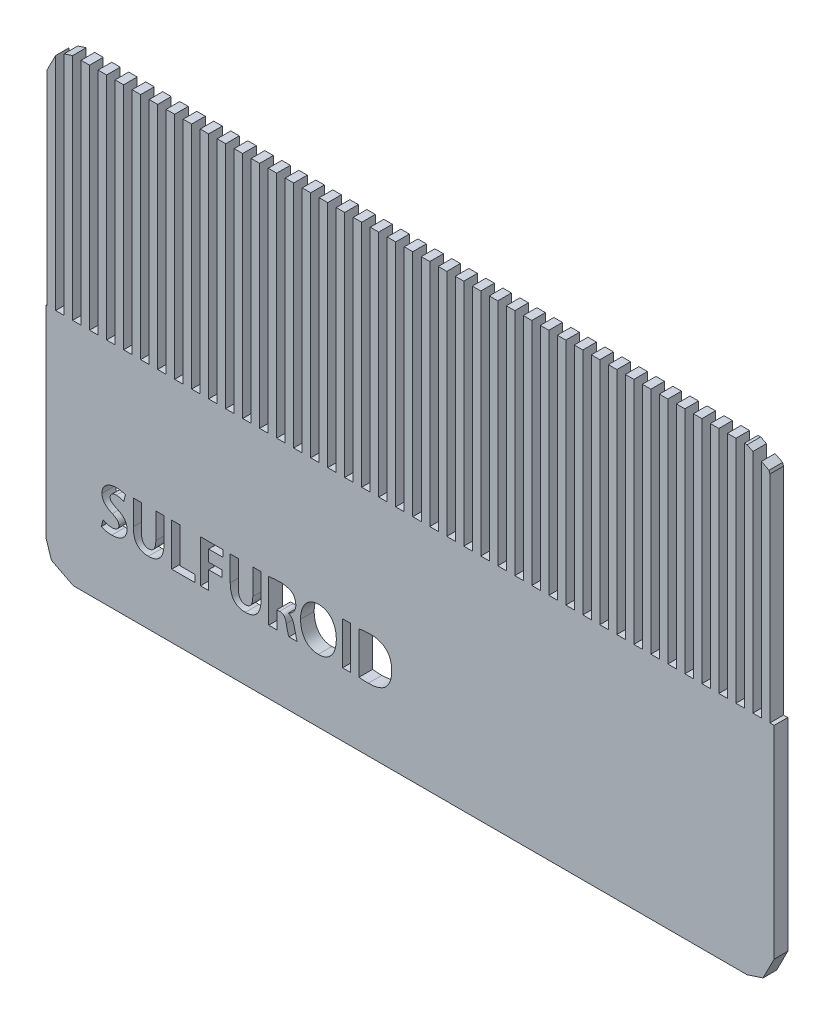
from build123d import *

# Parameters (mm, degrees)
BOSS_EXTRU_1_DEPTH      = 1.6
ESQUISSE2_W             = 0.957768643
ESQUISSE2_H             = 5
ENL_V_MAT_EXTRU_1_DEPTH = 1.6
ESQUISSE3_W             = 1.870037925
ESQUISSE3_H             = 1.835881981
ESQUISSE3_W_2           = 2.301837367
ESQUISSE3_H_2           = 4.041085352
ENL_V_MAT_EXTRU_2_DEPTH = 1.6
ESQUISSE4_W             = 2.558375981
ESQUISSE4_H             = 3.956558203
ENL_V_MAT_EXTRU_3_DEPTH = 1.6


with BuildPart() as part:
    # Model → Boss.-Extru.1 (new body)
    with BuildSketch(Plane.XY):
        Polygon((39.3, 0), (38.3, 0), (38.3, 26.99), (37.3, 26.99), (37.3, 0), (36.3, 0), (36.3, 26.99), (35.3, 26.99), (35.3, 0), (34.3, 0), (34.3, 26.99), (33.3, 26.99), (33.3, 0), (32.3, 0), (32.3, 26.99), (31.3, 26.99), (31.3, 0), (30.3, 0), (30.3, 26.99), (29.3, 26.99), (29.3, 0), (28.3, 0), (28.3, 26.99), (27.3, 26.99), (27.3, 0), (26.3, 0), (26.3, 26.99), (25.3, 26.99), (25.3, 0), (24.3, 0), (24.3, 26.99), (23.3, 26.99), (23.3, 0), (22.3, 0), (22.3, 26.99), (21.3, 26.99), (21.3, 0), (20.3, 0), (20.3, 26.99), (19.3, 26.99), (19.3, 0), (18.3, 0), (18.3, 26.99), (17.3, 26.99), (17.3, 0), (16.3, 0), (16.3, 26.99), (15.3, 26.99), (15.3, 0), (14.3, 0), (14.3, 26.99), (13.3, 26.99), (13.3, 0), (12.3, 0), (12.3, 26.99), (11.3, 26.99), (11.3, 0), (10.3, 0), (10.3, 26.99), (9.29999, 26.99), (9.29999, 0), (8.29999, 0), (8.29999, 26.99), (7.29999, 26.99), (7.29999, 0), (6.29999, 0), (6.29999, 26.99), (5.29999, 26.99), (5.29999, 0), (4.29999, 0), (4.29999, 26.99), (3.29999, 26.99), (3.29999, 0), (2.29999, 0), (2.29999, 26.99), (1.29999, 26.99), (1.29999, 0), (0.299988, 0), (0.299988, 26.99), (-0.699997, 26.99), (-0.699997, 0), (-1.7, 0), (-1.7, 26.99), (-2.7, 26.99), (-2.7, 0), (-3.7, 0), (-3.7, 26.99), (-4.7, 26.99), (-4.7, 0), (-5.7, 0), (-5.7, 26.99), (-6.7, 26.99), (-6.7, 0), (-7.7, 0), (-7.7, 26.99), (-8.7, 26.99), (-8.7, 0), (-9.7, 0), (-9.7, 26.99), (-10.7, 26.99), (-10.7, 0), (-11.7, 0), (-11.7, 26.99), (-12.7, 26.99), (-12.7, 0), (-13.7, 0), (-13.7, 26.99), (-14.7, 26.99), (-14.7, 0), (-15.7, 0), (-15.7, 26.99), (-16.7, 26.99), (-16.7, 0), (-17.7, 0), (-17.7, 26.99), (-18.7, 26.99), (-18.7, 0), (-19.7, 0), (-19.7, 26.99), (-20.7, 26.99), (-20.7, 0), (-21.7, 0), (-21.7, 26.99), (-22.7, 26.99), (-22.7, 0), (-23.7, 0), (-23.7, 26.99), (-24.7, 26.99), (-24.7, 0), (-25.7, 0), (-25.7, 26.99), (-26.7, 26.99), (-26.7, 0), (-27.7, 0), (-27.7, 26.99), (-28.7, 26.99), (-28.7, 0), (-29.7, 0), (-29.7, 26.99), (-30.7, 26.99), (-30.7, 0), (-31.7, 0), (-31.7, 26.99), (-32.7, 26.99), (-32.7, 0), (-33.7, 0), (-33.7, 26.99), (-34.7, 26.99), (-34.7, 0), (-35.7, 0), (-35.7, 26.99), (-36.7, 26.99), (-36.7, 0), (-37.7, 0), (-37.7, 26.99), (-38.7, 26.99), (-38.7, 0), (-39.7, 0), (-39.7, 26.964), (-40.7, 26.6391), (-40.7, 0), (-41.7, 0), (-41.7, 25.9689), (-42.7, 24.0062), (-42.7, 0), (-42.8, 0), (-42.8, -23.81), (-42.1927, -25.6792), (-39.62, -26.99), (39.62, -26.99), (41.4892, -26.3827), (42.8, -23.81), (42.8, 0), (42.3, 0), (42.3, 25.3489), (42.1927, 25.6792), (41.3, 26.134), (41.3, 0), (40.3, 0), (40.3, 26.6435), (39.62, 26.99), (39.3, 26.99), align=None)
    extrude(amount=BOSS_EXTRU_1_DEPTH)

    # Esquisse2 → Enlèv. mat.-Extru.1 (cut)
    with BuildSketch(Plane.XY.offset(1.6)):
        with BuildLine():
            add(Edge.make_bspline(
                [(-36.312470517, -19.306454231), (-36.279474655, -19.324711699), (-36.209064635, -19.363671391), (-36.088962995, -19.409811898), (-35.952171821, -19.455778709), (-35.798193871, -19.49473218), (-35.632974565, -19.529762273), (-35.459494376, -19.554980365), (-35.280421383, -19.571360242), (-35.158858991, -19.574328257), (-35.09723478, -19.575832847)],
                knots=[0, 0, 0, 0, 0.000113007, 0.000241146, 0.00038513, 0.000545869, 0.000717253, 0.000891632, 0.001071458, 0.001256342, 0.001256342, 0.001256342, 0.001256342], degree=3))
            add(Edge.make_bspline(
                [(-35.09723478, -19.575832847), (-35.027093735, -19.574069767), (-34.890559652, -19.570637816), (-34.692582293, -19.547979016), (-34.506627472, -19.516173066), (-34.333807634, -19.469321879), (-34.172521707, -19.412776218), (-34.024586927, -19.341417012), (-33.88891563, -19.258252947), (-33.76604355, -19.163240207), (-33.657978813, -19.056815715), (-33.561273009, -18.944188793), (-33.482434598, -18.820903897), (-33.415125111, -18.691430687), (-33.364878924, -18.5523391), (-33.326277761, -18.405838764), (-33.305205447, -18.250390121), (-33.301449673, -18.144265402), (-33.299534931, -18.090161656)],
                knots=[0, 0, 0, 0, 0.00021039, 0.000409537, 0.000597226, 0.000775815, 0.000946076, 0.001109247, 0.001267531, 0.00142272, 0.001574046, 0.001721904, 0.001867019, 0.002012049, 0.002158793, 0.002309696, 0.002465809, 0.002628173, 0.002628173, 0.002628173, 0.002628173], degree=3))
            add(Edge.make_bspline(
                [(-33.299534931, -18.090161656), (-33.300208149, -18.049602103), (-33.301536913, -17.969547668), (-33.313596729, -17.851511987), (-33.33606334, -17.738027787), (-33.364325348, -17.627713701), (-33.404788362, -17.522634571), (-33.451671255, -17.420623841), (-33.508834342, -17.323555707), (-33.573949614, -17.229592281), (-33.649168188, -17.139834987), (-33.733415227, -17.052695485), (-33.827683966, -16.968930879), (-33.932311978, -16.889006992), (-34.045225154, -16.810240783), (-34.168969833, -16.736195827), (-34.302409671, -16.665493425), (-34.395385703, -16.621413675), (-34.443011552, -16.598834356)],
                knots=[0, 0, 0, 0, 0.000121665, 0.000240136, 0.000355317, 0.000468506, 0.000581266, 0.000692603, 0.000804972, 0.000918729, 0.001035203, 0.00115587, 0.001282067, 0.001413114, 0.001550659, 0.001694868, 0.00184542, 0.002003527, 0.002003527, 0.002003527, 0.002003527], degree=3))
            add(Edge.make_bspline(
                [(-34.443011552, -16.598834356), (-34.47921524, -16.58232534), (-34.549432804, -16.550305871), (-34.65013341, -16.501509092), (-34.742809284, -16.453298735), (-34.827678512, -16.406151404), (-34.905463833, -16.360296557), (-34.97470925, -16.313840804), (-35.037327289, -16.27008434), (-35.091913342, -16.226119307), (-35.139925162, -16.181728193), (-35.180778454, -16.134333427), (-35.215108077, -16.083655738), (-35.24326105, -16.030663857), (-35.264415684, -15.974496096), (-35.279144599, -15.915990781), (-35.289441318, -15.854473453), (-35.289508376, -15.812364412), (-35.289542472, -15.790953511)],
                knots=[0, 0, 0, 0, 0.000119368, 0.000231516, 0.00033566, 0.000432715, 0.000522765, 0.000606431, 0.000682811, 0.000751859, 0.000816549, 0.000878716, 0.000939114, 0.000999835, 0.001058312, 0.001118673, 0.001180668, 0.001244799, 0.001244799, 0.001244799, 0.001244799], degree=3))
            add(Edge.make_bspline(
                [(-35.289542472, -15.790953511), (-35.287676923, -15.755197213), (-35.283982217, -15.684382135), (-35.250128276, -15.581847684), (-35.194096262, -15.486942667), (-35.129803971, -15.41630366), (-35.068154285, -15.365069788), (-35.013988356, -15.331520831), (-34.954288047, -15.301656825), (-34.887712784, -15.279015732), (-34.815888017, -15.258529919), (-34.737548704, -15.244817293), (-34.653069691, -15.236676125), (-34.594800549, -15.234178083), (-34.564617887, -15.23288413)],
                knots=[0, 0, 0, 0, 0.000107027, 0.000211966, 0.000320129, 0.000435603, 0.000496557, 0.00056011, 0.000626299, 0.00069637, 0.000770698, 0.000850209, 0.000934535, 0.001025156, 0.001025156, 0.001025156, 0.001025156], degree=3))
            add(Edge.make_bspline(
                [(-34.564617887, -15.23288413), (-34.515566178, -15.234507902), (-34.420724301, -15.237647478), (-34.283643184, -15.251572473), (-34.156978552, -15.274037661), (-34.040935236, -15.304252315), (-33.936261524, -15.339792654), (-33.841825968, -15.373916214), (-33.758935272, -15.40969258), (-33.708825966, -15.436202981), (-33.685093, -15.448758941)],
                knots=[0, 0, 0, 0, 0.000147207, 0.000284626, 0.000412955, 0.000532765, 0.000643958, 0.000744472, 0.000833968, 0.000914494, 0.000914494, 0.000914494, 0.000914494], degree=3))
            Line((-33.685093, -15.448758941), (-33.485053267, -14.676201157))
            add(Edge.make_bspline(
                [(-33.485053267, -14.676201157), (-33.516111292, -14.661978576), (-33.5809105, -14.632304697), (-33.685102768, -14.590767167), (-33.802130251, -14.556816242), (-33.929170088, -14.521594987), (-34.068085867, -14.493963661), (-34.217730561, -14.471677906), (-34.378430393, -14.46036957), (-34.488876021, -14.45755936), (-34.545764192, -14.456111882)],
                knots=[0, 0, 0, 0, 0.000102483, 0.00021382, 0.000336078, 0.000467788, 0.000609219, 0.000760666, 0.00092139, 0.00109211, 0.00109211, 0.00109211, 0.00109211], degree=3))
            add(Edge.make_bspline(
                [(-34.545764192, -14.456111882), (-34.611176688, -14.458402126), (-34.738543398, -14.46286153), (-34.923555915, -14.483514234), (-35.097302788, -14.516337341), (-35.259658203, -14.561600539), (-35.411461218, -14.617864557), (-35.551780022, -14.686923521), (-35.680918361, -14.768218678), (-35.797563744, -14.861854287), (-35.902455156, -14.964231436), (-35.99317631, -15.075305102), (-36.071434004, -15.192649488), (-36.134963447, -15.317970298), (-36.18386582, -15.450690162), (-36.219670952, -15.590275747), (-36.243073928, -15.737078122), (-36.2465037, -15.837683892), (-36.248252879, -15.888992727)],
                knots=[0, 0, 0, 0, 0.000196305, 0.000382231, 0.00055787, 0.000726207, 0.000887293, 0.001042859, 0.001194546, 0.001344124, 0.001490778, 0.001633447, 0.001773587, 0.001913133, 0.002053919, 0.002197049, 0.002344906, 0.002498798, 0.002498798, 0.002498798, 0.002498798], degree=3))
            add(Edge.make_bspline(
                [(-36.248252879, -15.888992727), (-36.246752181, -15.929269051), (-36.243786272, -16.008869277), (-36.227214789, -16.126155538), (-36.202231192, -16.239602502), (-36.166138958, -16.348867158), (-36.119300569, -16.453402589), (-36.065029126, -16.555033417), (-35.999214783, -16.651660872), (-35.923485097, -16.743767381), (-35.839732155, -16.832004589), (-35.748319396, -16.916578462), (-35.649497791, -16.997530918), (-35.542368115, -17.074600796), (-35.428598294, -17.149799034), (-35.305474893, -17.218441734), (-35.176282426, -17.286502), (-35.085854406, -17.326781328), (-35.039731009, -17.34732606)],
                knots=[0, 0, 0, 0, 0.000120844, 0.00023883, 0.000354781, 0.000468954, 0.000583334, 0.000698067, 0.000814155, 0.000933411, 0.001055441, 0.001178846, 0.001306791, 0.001438406, 0.00157463, 0.001715642, 0.001861103, 0.002012536, 0.002012536, 0.002012536, 0.002012536], degree=3))
            add(Edge.make_bspline(
                [(-35.039731009, -17.34732606), (-34.9757991, -17.376251168), (-34.855452468, -17.430700337), (-34.692103199, -17.521653059), (-34.55506601, -17.612845027), (-34.444994637, -17.708414011), (-34.357948474, -17.808848323), (-34.299182663, -17.920496558), (-34.261851161, -18.041276525), (-34.258841694, -18.125389253), (-34.257302653, -18.168404492)],
                knots=[0, 0, 0, 0, 0.00021043, 0.000396117, 0.000560318, 0.000703271, 0.000832418, 0.000956409, 0.001079299, 0.001207922, 0.001207922, 0.001207922, 0.001207922], degree=3))
            add(Edge.make_bspline(
                [(-34.257302653, -18.168404492), (-34.257745864, -18.191692007), (-34.258612238, -18.237213638), (-34.268307565, -18.303581771), (-34.28412283, -18.366290465), (-34.307341498, -18.425100739), (-34.335313919, -18.481142243), (-34.370588326, -18.533312136), (-34.412398465, -18.581665386), (-34.460506491, -18.625891728), (-34.514608117, -18.665623394), (-34.574575159, -18.700780064), (-34.640560705, -18.730834446), (-34.71257743, -18.755344452), (-34.790602851, -18.773916987), (-34.874338819, -18.788124242), (-34.964472371, -18.796396524), (-35.026517253, -18.798152854), (-35.058584704, -18.7990606)],
                knots=[0, 0, 0, 0, 6.9816e-05, 0.000136474, 0.000200722, 0.000263394, 0.00032579, 0.000388278, 0.000451775, 0.000517154, 0.000583898, 0.000652772, 0.000725328, 0.000801049, 0.000880615, 0.000965697, 0.001055653, 0.001151881, 0.001151881, 0.001151881, 0.001151881], degree=3))
            add(Edge.make_bspline(
                [(-35.058584704, -18.7990606), (-35.108892106, -18.797434691), (-35.208771907, -18.794206626), (-35.357219432, -18.779271406), (-35.502648759, -18.753545182), (-35.643964043, -18.718930449), (-35.778455758, -18.676634093), (-35.904338994, -18.629853179), (-36.01981336, -18.57744101), (-36.091097528, -18.536886067), (-36.12570386, -18.517197855)],
                knots=[0, 0, 0, 0, 0.000150974, 0.000299742, 0.00044713, 0.000593686, 0.000735907, 0.000869851, 0.000996395, 0.001115793, 0.001115793, 0.001115793, 0.001115793], degree=3))
            Line((-36.12570386, -18.517197855), (-36.312470517, -19.306454231))
        make_face()
        with BuildLine():
            Line((-29.912470407, -14.515501943), (-29.912470407, -17.538004307))
            add(Edge.make_bspline(
                [(-29.912470407, -17.538004307), (-29.913512385, -17.591674246), (-29.915521021, -17.695134522), (-29.926931296, -17.844189078), (-29.94432453, -17.981873326), (-29.969700589, -18.108171888), (-30.001525298, -18.223598771), (-30.03974418, -18.328129043), (-30.086054834, -18.42100553), (-30.139064335, -18.503057926), (-30.198697125, -18.573899718), (-30.263785552, -18.635382454), (-30.334244253, -18.687279048), (-30.410710151, -18.729222677), (-30.492441872, -18.761471834), (-30.579522851, -18.783830256), (-30.672147953, -18.797520074), (-30.73569707, -18.798536907), (-30.768426333, -18.7990606)],
                knots=[0, 0, 0, 0, 0.000161012, 0.000310385, 0.000448243, 0.000577102, 0.000696492, 0.000807156, 0.000910443, 0.001007187, 0.001099522, 0.001187551, 0.001275225, 0.001361294, 0.001448471, 0.0015381, 0.001630488, 0.0017286, 0.0017286, 0.0017286, 0.0017286], degree=3))
            add(Edge.make_bspline(
                [(-30.768426333, -18.7990606), (-30.79957678, -18.798479895), (-30.860606281, -18.797342187), (-30.949688278, -18.784211972), (-31.033491659, -18.760321449), (-31.112521285, -18.726885523), (-31.187187985, -18.68460428), (-31.256549558, -18.632276525), (-31.320303298, -18.569794085), (-31.379816092, -18.498077531), (-31.433808588, -18.415835554), (-31.47987939, -18.322246689), (-31.519601679, -18.218179164), (-31.550971305, -18.102774535), (-31.576258601, -17.977099731), (-31.595133263, -17.840817511), (-31.606143759, -17.693468433), (-31.608223871, -17.591499842), (-31.609301145, -17.538691068)],
                knots=[0, 0, 0, 0, 9.3402e-05, 0.000182992, 0.000269231, 0.000354146, 0.000439852, 0.000526014, 0.000614012, 0.000707071, 0.000805119, 0.000908407, 0.001019404, 0.001138794, 0.001266728, 0.001403778, 0.001551271, 0.001709712, 0.001709712, 0.001709712, 0.001709712], degree=3))
            Line((-31.609301145, -17.538691068), (-31.609301145, -14.515501943))
            Line((-31.609301145, -14.515501943), (-32.567069788, -14.515501943))
            Line((-32.567069788, -14.515501943), (-32.567069788, -17.453500535))
            add(Edge.make_bspline(
                [(-32.567069788, -17.453500535), (-32.565626608, -17.541958869), (-32.562834976, -17.713069243), (-32.541352857, -17.960496586), (-32.504920491, -18.189592783), (-32.454162761, -18.400491277), (-32.390532159, -18.593940889), (-32.312498024, -18.769820438), (-32.219016139, -18.927042039), (-32.111545, -19.066209437), (-31.9907998, -19.188023974), (-31.856953626, -19.293022899), (-31.710828174, -19.382790441), (-31.550944335, -19.453717309), (-31.379855069, -19.511378992), (-31.195490156, -19.548470054), (-30.999444234, -19.573360782), (-30.864350481, -19.574992862), (-30.794821507, -19.575832847)],
                knots=[0, 0, 0, 0, 0.000265351, 0.000513284, 0.000744357, 0.000960651, 0.001163361, 0.001354506, 0.001536707, 0.001710747, 0.001880726, 0.00204989, 0.002219971, 0.002393793, 0.00257355, 0.00276047, 0.002957024, 0.003165462, 0.003165462, 0.003165462, 0.003165462], degree=3))
            add(Edge.make_bspline(
                [(-30.794821507, -19.575832847), (-30.724367889, -19.574910191), (-30.587117884, -19.573112773), (-30.38727965, -19.549195951), (-30.199530421, -19.508612993), (-30.023598926, -19.45254176), (-29.859993395, -19.379195085), (-29.708004829, -19.29050015), (-29.568441736, -19.184063151), (-29.441875918, -19.060743749), (-29.327046239, -18.921337608), (-29.229649608, -18.762372388), (-29.144901174, -18.58670377), (-29.076884962, -18.3926894), (-29.023222004, -18.181311249), (-28.985202949, -17.952381897), (-28.961678569, -17.705713371), (-28.957699191, -17.535288528), (-28.955643528, -17.447250645)],
                knots=[0, 0, 0, 0, 0.000211264, 0.000411562, 0.000602565, 0.000786801, 0.000964449, 0.001139382, 0.001313596, 0.001489593, 0.001668477, 0.001853937, 0.002047465, 0.002252603, 0.00246958, 0.00270096, 0.002948127, 0.003212247, 0.003212247, 0.003212247, 0.003212247], degree=3))
            Line((-28.955643528, -17.447250645), (-28.954701764, -14.515501943))
            Line((-28.954701764, -14.515501943), (-29.912470407, -14.515501943))
        make_face()
        Polygon((-27.084414267, -18.679928813), (-27.084414267, -14.515501943), (-28.04218291, -14.515501943), (-28.04218291, -19.51396916), (-25.292530709, -19.51396916), (-25.292530709, -18.679928813), align=None)
        Polygon((-23.705832065, -17.403888067), (-22.102910773, -17.403888067), (-22.102910773, -16.627115819), (-23.705832065, -16.627115819), (-23.705832065, -15.292275111), (-21.985623849, -15.292275111), (-21.985623849, -14.515501943), (-24.663600708, -14.515501943), (-24.663600708, -19.515501943), (-23.705832065, -19.515501943), align=None)
        with BuildLine():
            Line((-18.509755475, -14.515501943), (-18.509755475, -17.538004307))
            add(Edge.make_bspline(
                [(-18.509755475, -17.538004307), (-18.510797453, -17.591674246), (-18.512806089, -17.695134522), (-18.524216364, -17.844189078), (-18.541609598, -17.981873326), (-18.566985657, -18.108171888), (-18.598810366, -18.223598771), (-18.637029248, -18.328129043), (-18.683339902, -18.42100553), (-18.736349403, -18.503057926), (-18.795982193, -18.573899718), (-18.86107062, -18.635382454), (-18.931529321, -18.687279048), (-19.007995219, -18.729222677), (-19.08972694, -18.761471834), (-19.176807919, -18.783830256), (-19.269433021, -18.797520074), (-19.332982138, -18.798536907), (-19.365711401, -18.7990606)],
                knots=[0, 0, 0, 0, 0.000161012, 0.000310385, 0.000448243, 0.000577102, 0.000696492, 0.000807156, 0.000910443, 0.001007187, 0.001099522, 0.001187551, 0.001275225, 0.001361294, 0.001448471, 0.0015381, 0.001630488, 0.0017286, 0.0017286, 0.0017286, 0.0017286], degree=3))
            add(Edge.make_bspline(
                [(-19.365711401, -18.7990606), (-19.396861848, -18.798479895), (-19.457891349, -18.797342187), (-19.546973346, -18.784211972), (-19.630776727, -18.760321449), (-19.709806353, -18.726885523), (-19.784473053, -18.68460428), (-19.853834626, -18.632276525), (-19.917588366, -18.569794085), (-19.97710116, -18.498077531), (-20.031093656, -18.415835554), (-20.077164458, -18.322246689), (-20.116886747, -18.218179164), (-20.148256373, -18.102774535), (-20.173543669, -17.977099731), (-20.19241833, -17.840817511), (-20.203428827, -17.693468433), (-20.205508938, -17.591499842), (-20.206586213, -17.538691068)],
                knots=[0, 0, 0, 0, 9.3402e-05, 0.000182992, 0.000269231, 0.000354146, 0.000439852, 0.000526014, 0.000614012, 0.000707071, 0.000805119, 0.000908407, 0.001019404, 0.001138794, 0.001266728, 0.001403778, 0.001551271, 0.001709712, 0.001709712, 0.001709712, 0.001709712], degree=3))
            Line((-20.206586213, -17.538691068), (-20.206586213, -14.515501943))
            Line((-20.206586213, -14.515501943), (-21.164354856, -14.515501943))
            Line((-21.164354856, -14.515501943), (-21.164354856, -17.453500535))
            add(Edge.make_bspline(
                [(-21.164354856, -17.453500535), (-21.162911676, -17.541958869), (-21.160120044, -17.713069243), (-21.138637925, -17.960496586), (-21.102205559, -18.189592783), (-21.051447829, -18.400491277), (-20.987817227, -18.593940889), (-20.909783092, -18.769820438), (-20.816301207, -18.927042039), (-20.708830068, -19.066209437), (-20.588084868, -19.188023974), (-20.454238694, -19.293022899), (-20.308113242, -19.382790441), (-20.148229403, -19.453717309), (-19.977140137, -19.511378992), (-19.792775224, -19.548470054), (-19.596729302, -19.573360782), (-19.461635549, -19.574992862), (-19.392106575, -19.575832847)],
                knots=[0, 0, 0, 0, 0.000265351, 0.000513284, 0.000744357, 0.000960651, 0.001163361, 0.001354506, 0.001536707, 0.001710747, 0.001880726, 0.00204989, 0.002219971, 0.002393793, 0.00257355, 0.00276047, 0.002957024, 0.003165462, 0.003165462, 0.003165462, 0.003165462], degree=3))
            add(Edge.make_bspline(
                [(-19.392106575, -19.575832847), (-19.321652956, -19.574910191), (-19.184402952, -19.573112773), (-18.984564718, -19.549195951), (-18.796815489, -19.508612993), (-18.620883994, -19.45254176), (-18.457278463, -19.379195085), (-18.305289897, -19.29050015), (-18.165726803, -19.184063151), (-18.039160986, -19.060743749), (-17.924331307, -18.921337608), (-17.826934676, -18.762372388), (-17.742186242, -18.58670377), (-17.674170029, -18.3926894), (-17.620507072, -18.181311249), (-17.582488017, -17.952381897), (-17.558963637, -17.705713371), (-17.554984259, -17.535288528), (-17.552928596, -17.447250645)],
                knots=[0, 0, 0, 0, 0.000211264, 0.000411562, 0.000602565, 0.000786801, 0.000964449, 0.001139382, 0.001313596, 0.001489593, 0.001668477, 0.001853937, 0.002047465, 0.002252603, 0.00246958, 0.00270096, 0.002948127, 0.003212247, 0.003212247, 0.003212247, 0.003212247], degree=3))
            Line((-17.552928596, -17.447250645), (-17.551986832, -14.515501943))
            Line((-17.551986832, -14.515501943), (-18.509755475, -14.515501943))
        make_face()
        with BuildLine():
            Line((-16.639467978, -19.515501943), (-15.681699335, -19.515501943))
            Line((-15.681699335, -19.515501943), (-15.681699335, -17.464219892))
            Line((-15.681699335, -17.464219892), (-15.356546738, -17.464219892))
            add(Edge.make_bspline(
                [(-15.356546738, -17.464219892), (-15.329479258, -17.464414306), (-15.276824101, -17.464792506), (-15.200195221, -17.472541258), (-15.128110554, -17.485338485), (-15.060687371, -17.505099942), (-14.99833508, -17.531834602), (-14.940190625, -17.563506291), (-14.888187458, -17.6029068), (-14.840031997, -17.647740999), (-14.796283985, -17.700971647), (-14.754496848, -17.762107234), (-14.717702057, -17.833652914), (-14.681085178, -17.912745443), (-14.65016485, -18.001900166), (-14.619217622, -18.098996936), (-14.593532588, -18.206015285), (-14.578222879, -18.280540279), (-14.570273996, -18.319234054)],
                knots=[0, 0, 0, 0, 8.1166e-05, 0.000157895, 0.000230745, 0.000300542, 0.000368126, 0.000433959, 0.000498628, 0.000563317, 0.000630908, 0.000704901, 0.000785029, 0.000871941, 0.000966171, 0.001067846, 0.001177591, 0.001296103, 0.001296103, 0.001296103, 0.001296103], degree=3))
            add(Edge.make_bspline(
                [(-14.570273996, -18.319234054), (-14.555814194, -18.393142284), (-14.528016822, -18.535222699), (-14.483231915, -18.737993638), (-14.441654801, -18.922513501), (-14.399043505, -19.085972354), (-14.360268357, -19.228295848), (-14.323201946, -19.346165005), (-14.292685015, -19.440740415), (-14.269277972, -19.493640395), (-14.259188023, -19.516443707)],
                knots=[0, 0, 0, 0, 0.000225918, 0.000434303, 0.000622957, 0.000793294, 0.000941043, 0.001065381, 0.001164057, 0.001238821, 0.001238821, 0.001238821, 0.001238821], degree=3))
            Line((-14.259188023, -19.516443707), (-13.273492343, -19.515501943))
            add(Edge.make_bspline(
                [(-13.273492343, -19.515501943), (-13.286759846, -19.485212322), (-13.317301923, -19.415484962), (-13.355297385, -19.292976433), (-13.399397902, -19.142338388), (-13.443481713, -18.965832089), (-13.491158538, -18.770366549), (-13.539263305, -18.562290091), (-13.591957164, -18.345508696), (-13.626160449, -18.197661472), (-13.64361487, -18.122212938)],
                knots=[0, 0, 0, 0, 9.9137e-05, 0.000228216, 0.00038425, 0.000570133, 0.000773851, 0.000987874, 0.001210805, 0.001443126, 0.001443126, 0.001443126, 0.001443126], degree=3))
            add(Edge.make_bspline(
                [(-13.64361487, -18.122212938), (-13.658293704, -18.060334612), (-13.686534983, -17.941284067), (-13.744021208, -17.773586327), (-13.808267678, -17.621898429), (-13.88264066, -17.487071755), (-13.967373066, -17.368778181), (-14.067048764, -17.270535993), (-14.179110813, -17.189455407), (-14.262528295, -17.151475088), (-14.304436892, -17.132393933)],
                knots=[0, 0, 0, 0, 0.000190683, 0.000366865, 0.000531122, 0.000684305, 0.00082798, 0.000965963, 0.001102506, 0.001240364, 0.001240364, 0.001240364, 0.001240364], degree=3))
            Line((-14.304436892, -17.132393933), (-14.303643342, -17.112508256))
            add(Edge.make_bspline(
                [(-14.303643342, -17.112508256), (-14.245474758, -17.087275799), (-14.129390053, -17.0369204), (-13.971481879, -16.929522527), (-13.826507036, -16.802126537), (-13.719346298, -16.678291669), (-13.644263576, -16.568305392), (-13.594325849, -16.480727152), (-13.55148179, -16.388746993), (-13.516870818, -16.292032228), (-13.488276515, -16.191020532), (-13.467785907, -16.085068079), (-13.454315172, -15.974793916), (-13.451693505, -15.89971493), (-13.450364493, -15.861654869)],
                knots=[0, 0, 0, 0, 0.000189855, 0.000378886, 0.000569905, 0.000767757, 0.00086816, 0.000969067, 0.001069868, 0.001172153, 0.00127691, 0.001384508, 0.001495589, 0.001609794, 0.001609794, 0.001609794, 0.001609794], degree=3))
            add(Edge.make_bspline(
                [(-13.450364493, -15.861654869), (-13.453036678, -15.822643598), (-13.458288001, -15.745979449), (-13.473964253, -15.634435132), (-13.492542018, -15.528017801), (-13.51580373, -15.427518603), (-13.544353099, -15.332505711), (-13.577146819, -15.242983981), (-13.614584857, -15.158992914), (-13.657487004, -15.081003571), (-13.704639077, -15.008720515), (-13.75509381, -14.940801473), (-13.812673736, -14.8809297), (-13.872785645, -14.824282295), (-13.939044735, -14.774912481), (-14.009276019, -14.729810239), (-14.084640409, -14.69152657), (-14.18990206, -14.648388399), (-14.323454146, -14.604216166), (-14.480701427, -14.554872411), (-14.63560107, -14.517873986), (-14.785695739, -14.486824866), (-14.932516107, -14.466766865), (-15.075230231, -14.452321339), (-15.214505041, -14.449955386), (-15.305896929, -14.454083079), (-15.350816982, -14.456111882)],
                knots=[0, 0, 0, 0, 0.000117272, 0.000230461, 0.000337712, 0.000441296, 0.000539715, 0.000635155, 0.000727138, 0.000815313, 0.00090186, 0.00098595, 0.001068649, 0.001150705, 0.001233474, 0.001316114, 0.001400856, 0.00148664, 0.001657164, 0.001822672, 0.001980889, 0.002134705, 0.002282286, 0.002425242, 0.002564788, 0.002699674, 0.002699674, 0.002699674, 0.002699674], degree=3))
            add(Edge.make_bspline(
                [(-15.350816982, -14.456111882), (-15.470888053, -14.457523493), (-15.705575437, -14.460282587), (-15.993729099, -14.479213882), (-16.212258884, -14.499648605), (-16.363757293, -14.516498711), (-16.505549427, -14.535113542), (-16.596449894, -14.549851711), (-16.640409742, -14.556979152)],
                knots=[0, 0, 0, 0, 0.000360185, 0.000704006, 0.000865909, 0.001018627, 0.001161281, 0.001294877, 0.001294877, 0.001294877, 0.001294877], degree=3))
            Line((-16.640409742, -14.556979152), (-16.639467978, -19.515501943))
        make_face()
        with BuildLine():
            add(Edge.make_bspline(
                [(-15.681699335, -15.210986041), (-15.657914846, -15.204889377), (-15.602191355, -15.190605808), (-15.50373359, -15.180571595), (-15.380180127, -15.172751114), (-15.289251749, -15.172622541), (-15.23958018, -15.172552304)],
                knots=[0, 0, 0, 0, 7.3576e-05, 0.000172379, 0.0002961, 0.000445057, 0.000445057, 0.000445057, 0.000445057], degree=3))
            add(Edge.make_bspline(
                [(-15.23958018, -15.172552304), (-15.192965432, -15.172286232), (-15.099293579, -15.171751563), (-14.959725346, -15.1988259), (-14.822543793, -15.245912952), (-14.711455636, -15.300682199), (-14.62821892, -15.358503001), (-14.572691753, -15.413225547), (-14.525670821, -15.478152224), (-14.485157543, -15.552656117), (-14.455469484, -15.638001021), (-14.430171542, -15.732013947), (-14.414672512, -15.836381662), (-14.410374078, -15.909371227), (-14.408132216, -15.947439182)],
                knots=[0, 0, 0, 0, 0.000139568, 0.000280461, 0.000423851, 0.000573937, 0.000650318, 0.000726977, 0.000806543, 0.000890055, 0.00098042, 0.00107691, 0.001181837, 0.001296217, 0.001296217, 0.001296217, 0.001296217], degree=3))
            add(Edge.make_bspline(
                [(-14.408132216, -15.947439182), (-14.409198107, -15.977014461), (-14.411280889, -16.034805363), (-14.422836079, -16.119018544), (-14.440588113, -16.198976799), (-14.465724914, -16.274409019), (-14.49939193, -16.345019104), (-14.539603706, -16.410954627), (-14.587669277, -16.471716024), (-14.641075844, -16.528521876), (-14.701572464, -16.579288574), (-14.767672489, -16.624055123), (-14.840511309, -16.660789055), (-14.918419494, -16.691748399), (-15.002319381, -16.71653078), (-15.091651211, -16.733968868), (-15.186808334, -16.745647307), (-15.252113671, -16.747675772), (-15.285771733, -16.748721234)],
                knots=[0, 0, 0, 0, 8.8738e-05, 0.000173396, 0.000254582, 0.000334176, 0.000411344, 0.000488787, 0.000565348, 0.000643364, 0.000722302, 0.000801784, 0.000882311, 0.000966511, 0.001053012, 0.001144341, 0.001239286, 0.001340263, 0.001340263, 0.001340263, 0.001340263], degree=3))
            Line((-15.285771733, -16.748721234), (-15.681699335, -16.747779469))
            Line((-15.681699335, -16.747779469), (-15.681699335, -15.210986041))
        make_face(mode=Mode.SUBTRACT)
        with BuildLine():
            add(Edge.make_bspline(
                [(-10.755212176, -14.455170118), (-10.836124067, -14.459242679), (-10.994375038, -14.46720797), (-11.224304033, -14.505596575), (-11.440983419, -14.563720561), (-11.644444779, -14.644010703), (-11.833866578, -14.747691598), (-12.010235843, -14.872052565), (-12.17397403, -15.017055734), (-12.320806011, -15.184583989), (-12.453721859, -15.368270615), (-12.569965887, -15.566817398), (-12.668073913, -15.779179334), (-12.749143606, -16.004446398), (-12.813525372, -16.243048667), (-12.859111879, -16.495325408), (-12.887720665, -16.760961482), (-12.892619923, -16.942527464), (-12.895123166, -17.035297403)],
                knots=[0, 0, 0, 0, 0.00024288, 0.000475035, 0.000697772, 0.000914837, 0.001129557, 0.001344019, 0.001561027, 0.001784063, 0.002010908, 0.002240329, 0.00247314, 0.002711696, 0.00295775, 0.00321365, 0.00348005, 0.003758372, 0.003758372, 0.003758372, 0.003758372], degree=3))
            add(Edge.make_bspline(
                [(-12.895123166, -17.035297403), (-12.893275076, -17.125551216), (-12.889654495, -17.302366897), (-12.862445341, -17.56092173), (-12.820695345, -17.807151514), (-12.761310741, -18.040837357), (-12.684996533, -18.261902956), (-12.592246506, -18.470378889), (-12.483595793, -18.666618863), (-12.358691188, -18.849061174), (-12.21897405, -19.01577437), (-12.062339036, -19.161316887), (-11.890417655, -19.284090871), (-11.705188765, -19.387331412), (-11.504437654, -19.467351717), (-11.289512784, -19.526555078), (-11.060081509, -19.564956591), (-10.902123924, -19.57214889), (-10.82121668, -19.575832847)],
                knots=[0, 0, 0, 0, 0.000270715, 0.000530355, 0.000779097, 0.001019395, 0.001252825, 0.001479862, 0.001703089, 0.00192482, 0.002142205, 0.002354328, 0.002564403, 0.002774537, 0.002988976, 0.003211054, 0.003442279, 0.003685079, 0.003685079, 0.003685079, 0.003685079], degree=3))
            add(Edge.make_bspline(
                [(-10.82121668, -19.575832847), (-10.743807175, -19.573927186), (-10.591798564, -19.570185049), (-10.370133055, -19.538300901), (-10.159636248, -19.48752785), (-9.960805308, -19.415997759), (-9.773611147, -19.32243264), (-9.597377962, -19.209548204), (-9.434699556, -19.073525754), (-9.282038584, -18.920299485), (-9.145039598, -18.745217893), (-9.025852702, -18.549127042), (-8.923809805, -18.333033706), (-8.840573372, -18.096572468), (-8.774555019, -17.840458206), (-8.727208226, -17.5642643), (-8.697030545, -17.267836837), (-8.691018102, -17.063336618), (-8.687921054, -16.957997252)],
                knots=[0, 0, 0, 0, 0.000232132, 0.000455837, 0.000670299, 0.000880828, 0.001088247, 0.00129691, 0.001507169, 0.001723145, 0.001944726, 0.002172364, 0.00241019, 0.00266035, 0.00292329, 0.003202721, 0.003500257, 0.003816332, 0.003816332, 0.003816332, 0.003816332], degree=3))
            add(Edge.make_bspline(
                [(-8.687921054, -16.957997252), (-8.68914325, -16.873717343), (-8.691547471, -16.707927656), (-8.717210889, -16.464524968), (-8.756223505, -16.230661009), (-8.811676728, -16.006340862), (-8.884565793, -15.791739809), (-8.973304065, -15.586887712), (-9.077371784, -15.391341123), (-9.197363326, -15.207121237), (-9.332828744, -15.036912256), (-9.486861798, -14.887403121), (-9.65799932, -14.760044643), (-9.84606126, -14.654944315), (-10.050503717, -14.572048324), (-10.270654385, -14.509455993), (-10.507567166, -14.470028063), (-10.671184462, -14.460834356), (-10.755212176, -14.455170118)],
                knots=[0, 0, 0, 0, 0.000252752, 0.000497197, 0.000733382, 0.000963617, 0.001189582, 0.001412513, 0.001632658, 0.001853334, 0.002071225, 0.00228389, 0.00249543, 0.002709411, 0.002928408, 0.003155789, 0.003394762, 0.003647164, 0.003647164, 0.003647164, 0.003647164], degree=3))
        make_face()
        with BuildLine():
            add(Edge.make_bspline(
                [(-10.781331172, -15.231943286), (-10.736680262, -15.235992122), (-10.649640452, -15.24388468), (-10.523807202, -15.271886054), (-10.407071769, -15.316952024), (-10.299454097, -15.37730045), (-10.200635236, -15.453386539), (-10.110895097, -15.544363149), (-10.030386054, -15.650992598), (-9.960512004, -15.771987309), (-9.899767847, -15.903319421), (-9.844092618, -16.041001941), (-9.799746821, -16.185767553), (-9.761489741, -16.336008761), (-9.732583093, -16.492552414), (-9.711928669, -16.655254598), (-9.699428514, -16.823937345), (-9.698173525, -16.938493649), (-9.697536439, -16.996647327)],
                knots=[0, 0, 0, 0, 0.000134417, 0.000262025, 0.000385272, 0.000508515, 0.000630882, 0.000758201, 0.000890744, 0.001030596, 0.001176502, 0.001324596, 0.001475758, 0.001630316, 0.001789507, 0.001952969, 0.002122154, 0.002296592, 0.002296592, 0.002296592, 0.002296592], degree=3))
            add(Edge.make_bspline(
                [(-9.697536439, -16.996647327), (-9.698474196, -17.059517118), (-9.700314307, -17.182883243), (-9.713772743, -17.363799826), (-9.735027719, -17.536305813), (-9.765444178, -17.700585954), (-9.803654821, -17.856545803), (-9.85049462, -18.004583661), (-9.907877738, -18.143294188), (-9.97064971, -18.27403554), (-10.042707549, -18.39313133), (-10.124149463, -18.497721606), (-10.213875069, -18.587576519), (-10.313311311, -18.660387686), (-10.419499736, -18.720199031), (-10.535137668, -18.762320363), (-10.658745562, -18.790447558), (-10.744392719, -18.796144954), (-10.788222714, -18.7990606)],
                knots=[0, 0, 0, 0, 0.000188596, 0.000370072, 0.00054394, 0.000709791, 0.000870979, 0.001025407, 0.00117508, 0.001320953, 0.001460155, 0.00159178, 0.001717765, 0.001839751, 0.001960429, 0.002082127, 0.002207688, 0.002339293, 0.002339293, 0.002339293, 0.002339293], degree=3))
            add(Edge.make_bspline(
                [(-10.788222714, -18.7990606), (-10.831726947, -18.796118142), (-10.916729404, -18.790368905), (-11.039978227, -18.762532148), (-11.154504784, -18.718736943), (-11.261946487, -18.660846259), (-11.360047231, -18.586131032), (-11.451725558, -18.497904304), (-11.533757188, -18.393140081), (-11.606251119, -18.274010935), (-11.671869291, -18.144788134), (-11.728482105, -18.006252104), (-11.77618748, -17.860280538), (-11.816037493, -17.706672134), (-11.8469011, -17.545115478), (-11.869460562, -17.375817706), (-11.882696747, -17.198593115), (-11.884556964, -17.078054758), (-11.885507781, -17.016443707)],
                knots=[0, 0, 0, 0, 0.000130666, 0.000255308, 0.000377337, 0.000497562, 0.000620111, 0.00074611, 0.000878318, 0.001018014, 0.001163883, 0.001312684, 0.001466507, 0.00162427, 0.001788444, 0.001959629, 0.002136404, 0.00232123, 0.00232123, 0.00232123, 0.00232123], degree=3))
            add(Edge.make_bspline(
                [(-11.885507781, -17.016443707), (-11.88488194, -16.957974852), (-11.883652364, -16.843102424), (-11.871041766, -16.673805534), (-11.850518228, -16.510451766), (-11.821303885, -16.352740156), (-11.783807676, -16.200917516), (-11.737453578, -16.055140133), (-11.682682151, -15.915299806), (-11.620227825, -15.782279923), (-11.550244698, -15.658378544), (-11.467598493, -15.550434621), (-11.376358237, -15.457518583), (-11.275449618, -15.380372484), (-11.165389384, -15.318588718), (-11.045738566, -15.272820769), (-10.916783066, -15.243490076), (-10.827333941, -15.236470998), (-10.781331172, -15.231943286)],
                knots=[0, 0, 0, 0, 0.00017538, 0.000344565, 0.000508963, 0.00066908, 0.000825467, 0.000977812, 0.00112766, 0.001275674, 0.001418443, 0.001553629, 0.00168228, 0.001808039, 0.001933388, 0.002059613, 0.002191106, 0.002328525, 0.002328525, 0.002328525, 0.002328525], degree=3))
        make_face(mode=Mode.SUBTRACT)
        with Locations((-7.472800852, -17.015501943)):
            Rectangle(ESQUISSE2_W, ESQUISSE2_H)
        with BuildLine():
            add(Edge.make_bspline(
                [(-6.021066771, -19.506727794), (-5.9874646, -19.511384283), (-5.916601387, -19.521204297), (-5.805320161, -19.533206849), (-5.683960312, -19.543300338), (-5.552950366, -19.552981568), (-5.412139792, -19.560265019), (-5.26161096, -19.565987454), (-5.101643687, -19.569459934), (-4.991654883, -19.57117839), (-4.935093, -19.572062108)],
                knots=[0, 0, 0, 0, 0.000101766, 0.000214613, 0.000335721, 0.000467093, 0.000608697, 0.00075869, 0.000918991, 0.001088698, 0.001088698, 0.001088698, 0.001088698], degree=3))
            add(Edge.make_bspline(
                [(-4.935093, -19.572062108), (-4.829759261, -19.570348215), (-4.624350728, -19.567005996), (-4.325405966, -19.538318619), (-4.043774351, -19.491940728), (-3.780731894, -19.425215018), (-3.536052048, -19.340301167), (-3.312560263, -19.233635827), (-3.107138699, -19.110787184), (-2.987246518, -19.009977715), (-2.928117133, -18.960259695)],
                knots=[0, 0, 0, 0, 0.00031594, 0.000616106, 0.000900024, 0.001171415, 0.001429313, 0.001675569, 0.001913396, 0.002144831, 0.002144831, 0.002144831, 0.002144831], degree=3))
            add(Edge.make_bspline(
                [(-2.928117133, -18.960259695), (-2.903352939, -18.937908051), (-2.853014737, -18.892473842), (-2.780826768, -18.817791019), (-2.712848472, -18.734268442), (-2.644827241, -18.645087234), (-2.582907098, -18.546043638), (-2.519611871, -18.441672508), (-2.461086245, -18.328527282), (-2.4038665, -18.20820325), (-2.350451554, -18.079468274), (-2.306125593, -17.940075125), (-2.265831249, -17.792170836), (-2.234825771, -17.634167787), (-2.207592372, -17.467038508), (-2.190023177, -17.290067058), (-2.175753064, -17.103703025), (-2.173328093, -16.976252254), (-2.17208395, -16.910863013)],
                knots=[0, 0, 0, 0, 0.000100067, 0.000203406, 0.00031119, 0.000422992, 0.000539615, 0.000661353, 0.000789117, 0.000921527, 0.001061047, 0.001206822, 0.001360028, 0.001520686, 0.001689616, 0.001867841, 0.002054018, 0.002250178, 0.002250178, 0.002250178, 0.002250178], degree=3))
            add(Edge.make_bspline(
                [(-2.17208395, -16.910863013), (-2.172937071, -16.855233355), (-2.17460597, -16.74640905), (-2.183893872, -16.586280847), (-2.200218453, -16.432555616), (-2.221188404, -16.284858411), (-2.249940557, -16.143727203), (-2.283650219, -16.009019081), (-2.322933312, -15.880371328), (-2.369470727, -15.758428566), (-2.421476374, -15.642496065), (-2.477814465, -15.531683586), (-2.540314901, -15.427137117), (-2.607196986, -15.327648068), (-2.67962196, -15.23438209), (-2.757742121, -15.147497219), (-2.839313019, -15.064653411), (-2.898492361, -15.014685202), (-2.928117133, -14.98967146)],
                knots=[0, 0, 0, 0, 0.000166898, 0.00032649, 0.000480981, 0.000630562, 0.000773841, 0.000912851, 0.001047031, 0.001177114, 0.001304129, 0.00142808, 0.001549818, 0.001669305, 0.001787536, 0.001903712, 0.002019697, 0.002135957, 0.002135957, 0.002135957, 0.002135957], degree=3))
            add(Edge.make_bspline(
                [(-2.928117133, -14.98967146), (-2.981274809, -14.947266194), (-3.088699843, -14.861570441), (-3.268816824, -14.754272989), (-3.465011759, -14.664013574), (-3.678130396, -14.588679574), (-3.910652757, -14.531986228), (-4.163989162, -14.490590759), (-4.439089215, -14.466530134), (-4.62992942, -14.463391505), (-4.728645036, -14.461767991)],
                knots=[0, 0, 0, 0, 0.000203814, 0.000411883, 0.000626982, 0.000850891, 0.0010889, 0.001343992, 0.001620345, 0.001916469, 0.001916469, 0.001916469, 0.001916469], degree=3))
            add(Edge.make_bspline(
                [(-4.728645036, -14.461767991), (-4.847773711, -14.46284271), (-5.080250678, -14.46494), (-5.366193438, -14.483359513), (-5.583936035, -14.50290819), (-5.736844801, -14.522493705), (-5.882214664, -14.542491978), (-5.976177756, -14.559199527), (-6.022008536, -14.567348685)],
                knots=[0, 0, 0, 0, 0.000357338, 0.000697338, 0.000859241, 0.001013116, 0.001159763, 0.001299398, 0.001299398, 0.001299398, 0.001299398], degree=3))
            Line((-6.022008536, -14.567348685), (-6.021066771, -19.506727794))
        make_face()
        with BuildLine():
            add(Edge.make_bspline(
                [(-5.063298128, -15.265379136), (-5.034756461, -15.260149887), (-4.972000116, -15.248652011), (-4.867998031, -15.238564374), (-4.746390826, -15.229461162), (-4.65922332, -15.228005192), (-4.61269481, -15.227228021)],
                knots=[0, 0, 0, 0, 8.7015e-05, 0.000191326, 0.000313228, 0.000452796, 0.000452796, 0.000452796, 0.000452796], degree=3))
            add(Edge.make_bspline(
                [(-4.61269481, -15.227228021), (-4.55827496, -15.228437479), (-4.452199403, -15.230794963), (-4.297767032, -15.250783232), (-4.15279183, -15.28420828), (-4.015879339, -15.328140909), (-3.889857591, -15.390355838), (-3.771234367, -15.462054067), (-3.663053139, -15.549332214), (-3.563556017, -15.648403158), (-3.474342057, -15.761473882), (-3.39679518, -15.888372644), (-3.332569456, -16.029077621), (-3.276471693, -16.18176934), (-3.236870107, -16.349105015), (-3.205123146, -16.528723505), (-3.186593875, -16.721950403), (-3.183366782, -16.855206709), (-3.181699335, -16.9240606)],
                knots=[0, 0, 0, 0, 0.000163218, 0.000318146, 0.000466102, 0.000609191, 0.000748329, 0.000886728, 0.001024234, 0.001164215, 0.001307171, 0.001455266, 0.0016092, 0.001770521, 0.001942454, 0.002124246, 0.002317475, 0.002524061, 0.002524061, 0.002524061, 0.002524061], degree=3))
            add(Edge.make_bspline(
                [(-3.181699335, -16.9240606), (-3.183593358, -17.003289044), (-3.187252746, -17.156364107), (-3.207746917, -17.377854366), (-3.241749168, -17.582482964), (-3.286129375, -17.771422036), (-3.344525781, -17.943474806), (-3.415081292, -18.099692672), (-3.499129597, -18.238820127), (-3.595159405, -18.361861291), (-3.702116208, -18.468505823), (-3.818006371, -18.560603409), (-3.942210264, -18.63888111), (-4.076383307, -18.701192968), (-4.219070862, -18.749036768), (-4.37027035, -18.783315472), (-4.530501907, -18.802197279), (-4.640298146, -18.803239598), (-4.696593754, -18.803774024)],
                knots=[0, 0, 0, 0, 0.000237708, 0.000459269, 0.000666628, 0.000859602, 0.001040852, 0.001210852, 0.001372846, 0.001527291, 0.001677938, 0.001824867, 0.001970556, 0.002117316, 0.002267561, 0.002421242, 0.002581667, 0.002750474, 0.002750474, 0.002750474, 0.002750474], degree=3))
            add(Edge.make_bspline(
                [(-4.696593754, -18.803774024), (-4.730221458, -18.804492221), (-4.795300679, -18.805882137), (-4.889916173, -18.801299676), (-4.978703191, -18.795539402), (-5.035678611, -18.787752458), (-5.063298128, -18.783977644)],
                knots=[0, 0, 0, 0, 0.000100872, 0.000195216, 0.000284073, 0.000367675, 0.000367675, 0.000367675, 0.000367675], degree=3))
            Line((-5.063298128, -18.783977644), (-5.063298128, -15.265379136))
        make_face(mode=Mode.SUBTRACT)
    extrude(amount=-ENL_V_MAT_EXTRU_1_DEPTH, mode=Mode.SUBTRACT)

    # Esquisse3 → Enlèv. mat.-Extru.2 (cut)
    with BuildSketch(Plane.XY.offset(1.6)):
        with Locations((-15.146083788, -15.973801186)):
            Rectangle(ESQUISSE3_W, ESQUISSE3_H)
        with Locations((-10.764333883, -16.891742176)):
            Rectangle(ESQUISSE3_W_2, ESQUISSE3_H_2)
    extrude(amount=-ENL_V_MAT_EXTRU_2_DEPTH, mode=Mode.SUBTRACT)

    # Esquisse4 → Enlèv. mat.-Extru.3 (cut)
    with BuildSketch(Plane.XY.offset(1.6)):
        with Locations((-4.40511495, -17.074701236)):
            Rectangle(ESQUISSE4_W, ESQUISSE4_H)
    extrude(amount=-ENL_V_MAT_EXTRU_3_DEPTH, mode=Mode.SUBTRACT)


solid = part.part
